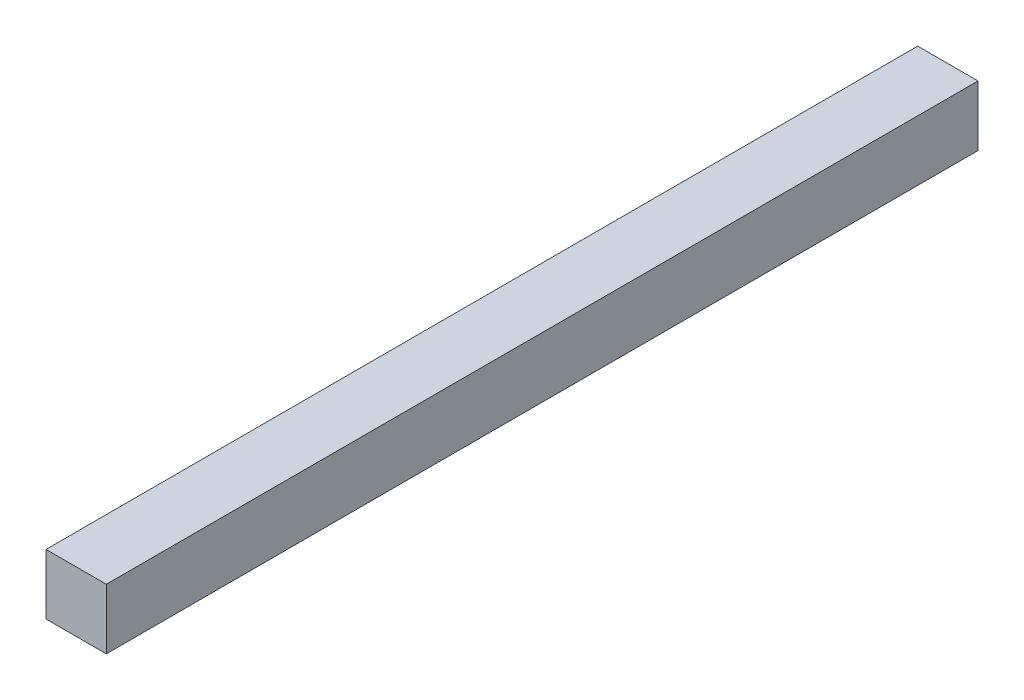
from build123d import *

# Parameters (mm, degrees)
SKIZZE1_W                          = 33
SKIZZE1_H                          = 33
AUFSATZ_LINEAR_AUSTRAGEN1_DEPTH    = 477
F_7_0_7_DURCHMESSER_BOHRUNG1_D     = 7
F_7_0_7_DURCHMESSER_BOHRUNG1_DEPTH = 22.25
F_7_0_7_DURCHMESSER_BOHRUNG1_TIP   = 2.103012167


with BuildPart() as part:
    # Skizze1 → Aufsatz-Linear austragen1 (new body)
    with BuildSketch(Plane.XY):
        Rectangle(SKIZZE1_W, SKIZZE1_H)
    extrude(amount=AUFSATZ_LINEAR_AUSTRAGEN1_DEPTH)

    # Ø7.0 (7) Durchmesser Bohrung1
    with Locations(Plane(origin=(0, -16.5, 0), x_dir=(-1, 0, 0), z_dir=(0, -1, 0))):
        with Locations((0, -437), (0, -349.5), (0, -262)):
            Hole(F_7_0_7_DURCHMESSER_BOHRUNG1_D / 2, depth=F_7_0_7_DURCHMESSER_BOHRUNG1_DEPTH)
            with Locations((0, 0, -(F_7_0_7_DURCHMESSER_BOHRUNG1_DEPTH + F_7_0_7_DURCHMESSER_BOHRUNG1_TIP / 2))):  # 118° drill point
                Cone(0, F_7_0_7_DURCHMESSER_BOHRUNG1_D / 2, F_7_0_7_DURCHMESSER_BOHRUNG1_TIP, mode=Mode.SUBTRACT)


solid = part.part
